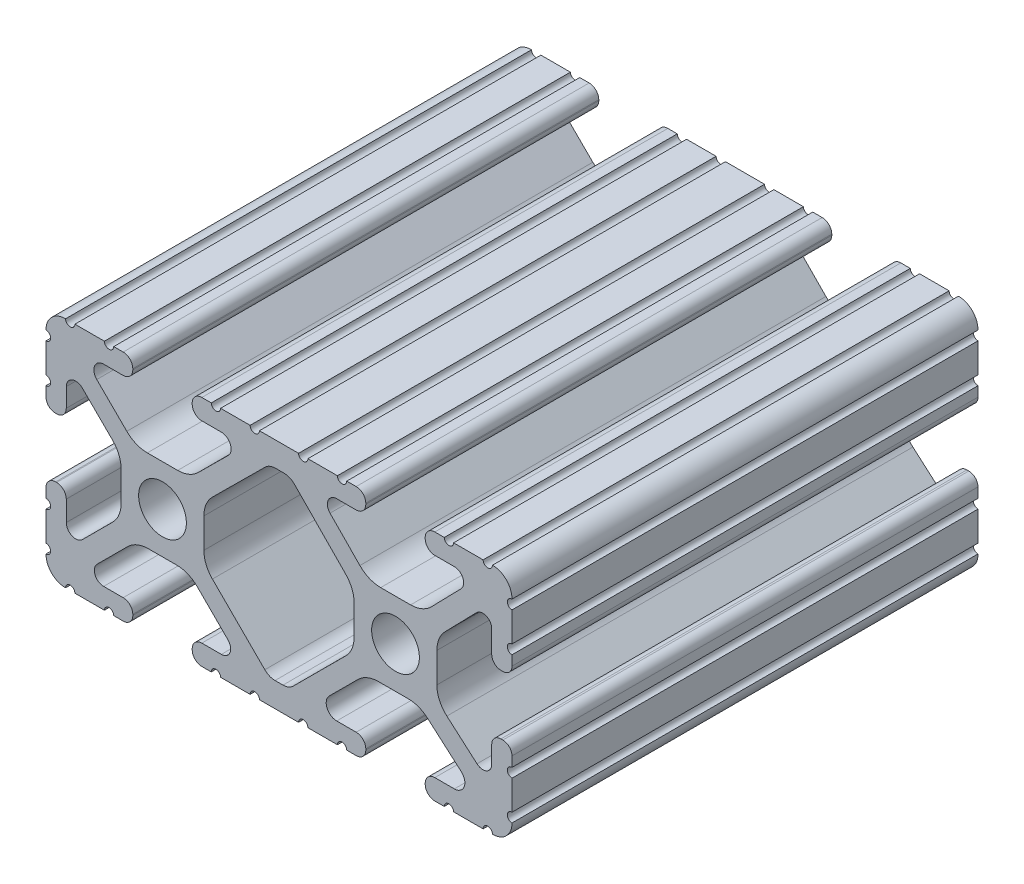
from build123d import *

# Parameters (mm, degrees)
SKETCH1_R           = 2.6035
BOSS_EXTRUDE1_DEPTH = 25.4


with BuildPart() as part:
    # Sketch1 → Boss-Extrude1 (new body, symmetric)
    with BuildSketch(Plane.XY):
        with BuildLine():
            Line((18.01710265, 12.7), (16.98745015, 12.7))
            ThreePointArc((16.98745015, 12.7), (16.245730386, 12.392769614), (15.9385, 11.65104985))
            Line((15.9385, 11.65104985), (15.9385, 11.53922))
            ThreePointArc((15.9385, 11.53922), (16.245750844, 10.797450844), (16.98752, 10.4902))
            Line((16.98752, 10.4902), (19.116384363, 10.4902))
            ThreePointArc((19.116384363, 10.4902), (20.052502933, 9.869096983), (19.844087081, 8.765172272))
            Line((19.844087081, 8.765172272), (16.618993479, 5.455112286))
            ThreePointArc((16.618993479, 5.455112286), (15.578994274, 4.745442459), (14.344932584, 4.4958))
            Line((14.344932584, 4.4958), (11.083317835, 4.4958))
            ThreePointArc((11.083317835, 4.4958), (9.854330953, 4.743306833), (8.816955189, 5.447238587))
            Line((8.816955189, 5.447238587), (5.564154119, 8.762652677))
            ThreePointArc((5.564154119, 8.762652677), (5.352591412, 9.867473037), (6.289393385, 10.4902))
            Line((6.289393385, 10.4902), (8.41248, 10.4902))
            ThreePointArc((8.41248, 10.4902), (9.154249156, 10.797450844), (9.4615, 11.53922))
            Line((9.4615, 11.53922), (9.4615, 11.65104985))
            ThreePointArc((9.4615, 11.65104985), (9.154269614, 12.392769614), (8.41254985, 12.7))
            Line((8.41254985, 12.7), (7.38288465, 12.7))
            ThreePointArc((7.38288465, 12.7), (6.87488465, 12.192), (6.36688465, 12.7))
            Line((6.36688465, 12.7), (3.14958095, 12.7))
            ThreePointArc((3.14958095, 12.7), (2.64158095, 12.192), (2.13358095, 12.7))
            Line((2.13358095, 12.7), (-2.13358095, 12.7))
            ThreePointArc((-2.13358095, 12.7), (-2.64158095, 12.192), (-3.14958095, 12.7))
            Line((-3.14958095, 12.7), (-6.36689735, 12.7))
            ThreePointArc((-6.36689735, 12.7), (-6.87489735, 12.192), (-7.38289735, 12.7))
            Line((-7.38289735, 12.7), (-8.41254985, 12.7))
            ThreePointArc((-8.41254985, 12.7), (-9.154269614, 12.392769614), (-9.4615, 11.65104985))
            Line((-9.4615, 11.65104985), (-9.4615, 11.53922))
            ThreePointArc((-9.4615, 11.53922), (-9.154249156, 10.797450844), (-8.41248, 10.4902))
            Line((-8.41248, 10.4902), (-6.283641037, 10.4902))
            ThreePointArc((-6.283641037, 10.4902), (-5.297291557, 9.829633109), (-5.532576693, 8.666071843))
            Line((-5.532576693, 8.666071843), (-8.809985098, 5.416263103))
            ThreePointArc((-8.809985098, 5.416263103), (-9.836720513, 4.734920264), (-11.045536121, 4.4958))
            Line((-11.045536121, 4.4958), (-14.354463879, 4.4958))
            ThreePointArc((-14.354463879, 4.4958), (-15.563279487, 4.734920264), (-16.590014902, 5.416263103))
            Line((-16.590014902, 5.416263103), (-19.867423307, 8.666071843))
            ThreePointArc((-19.867423307, 8.666071843), (-20.102708443, 9.829633109), (-19.116358963, 10.4902))
            Line((-19.116358963, 10.4902), (-16.98752, 10.4902))
            ThreePointArc((-16.98752, 10.4902), (-16.245750844, 10.797450844), (-15.9385, 11.53922))
            Line((-15.9385, 11.53922), (-15.9385, 11.65104985))
            ThreePointArc((-15.9385, 11.65104985), (-16.245730386, 12.392769614), (-16.98745015, 12.7))
            Line((-16.98745015, 12.7), (-18.01711535, 12.7))
            ThreePointArc((-18.01711535, 12.7), (-18.52511535, 12.192), (-19.03311535, 12.7))
            Line((-19.03311535, 12.7), (-22.2504, 12.7))
            ThreePointArc((-22.2504, 12.7), (-22.758323491, 12.192000006), (-23.266399977, 12.699846982))
            ThreePointArc((-23.266399977, 12.699846982), (-24.782522516, 12.082522516), (-25.399846982, 10.566399977))
            ThreePointArc((-25.399846982, 10.566399977), (-24.892000006, 10.058323491), (-25.4, 9.5504))
            Line((-25.4, 9.5504), (-25.4, 6.3330836))
            ThreePointArc((-25.4, 6.3330836), (-24.892, 5.8250836), (-25.4, 5.3170836))
            Line((-25.4, 5.3170836), (-25.4, 4.237520184))
            ThreePointArc((-25.4, 4.237520184), (-25.107393763, 3.531106237), (-24.400979816, 3.2385))
            Line((-24.400979816, 3.2385), (-24.23922, 3.2385))
            ThreePointArc((-24.23922, 3.2385), (-23.497450844, 3.545750844), (-23.1902, 4.28752))
            Line((-23.1902, 4.28752), (-23.1902, 6.334741132))
            ThreePointArc((-23.1902, 6.334741132), (-22.556026952, 7.286023527), (-21.434002553, 7.066535717))
            Line((-21.434002553, 7.066535717), (-18.147950853, 3.808156468))
            ThreePointArc((-18.147950853, 3.808156468), (-17.452759693, 2.774838327), (-17.208501877, 1.553619571))
            Line((-17.208501877, 1.553619571), (-17.208501877, -1.695179196))
            ThreePointArc((-17.208501877, -1.695179196), (-17.450738657, -2.911536421), (-18.140486065, -3.942289578))
            Line((-18.140486065, -3.942289578), (-21.431579576, -7.227386226))
            ThreePointArc((-21.431579576, -7.227386226), (-22.55444896, -7.449940594), (-23.1902, -6.498002195))
            Line((-23.1902, -6.498002195), (-23.1902, -4.28752))
            ThreePointArc((-23.1902, -4.28752), (-23.497450844, -3.545750844), (-24.23922, -3.2385))
            Line((-24.23922, -3.2385), (-24.35098, -3.2385))
            ThreePointArc((-24.35098, -3.2385), (-25.092749156, -3.545750844), (-25.4, -4.28752))
            Line((-25.4, -4.28752), (-25.4, -5.3171344))
            ThreePointArc((-25.4, -5.3171344), (-24.892, -5.8251344), (-25.4, -6.3331344))
            Line((-25.4, -6.3331344), (-25.4, -9.5504))
            ThreePointArc((-25.4, -9.5504), (-24.892000006, -10.058323491), (-25.399846982, -10.566399977))
            ThreePointArc((-25.399846982, -10.566399977), (-24.782522516, -12.082522516), (-23.266399977, -12.699846982))
            ThreePointArc((-23.266399977, -12.699846982), (-22.758323491, -12.192000006), (-22.2504, -12.7))
            Line((-22.2504, -12.7), (-19.03308995, -12.7))
            ThreePointArc((-19.03308995, -12.7), (-18.52508995, -12.192), (-18.01708995, -12.7))
            Line((-18.01708995, -12.7), (-16.9874692, -12.7))
            ThreePointArc((-16.9874692, -12.7), (-16.245700044, -12.392749156), (-15.9384492, -11.65098))
            Line((-15.9384492, -11.65098), (-15.9384492, -11.53922))
            ThreePointArc((-15.9384492, -11.53922), (-16.245700044, -10.797450844), (-16.9874692, -10.4902))
            Line((-16.9874692, -10.4902), (-19.116358963, -10.4902))
            ThreePointArc((-19.116358963, -10.4902), (-20.055197748, -9.862578342), (-19.834124023, -8.755124678))
            Line((-19.834124023, -8.755124678), (-16.49660751, -5.423689618))
            ThreePointArc((-16.49660751, -5.423689618), (-15.467274017, -4.736928798), (-14.253591699, -4.4958))
            Line((-14.253591699, -4.4958), (-11.146408301, -4.4958))
            ThreePointArc((-11.146408301, -4.4958), (-9.932725983, -4.736928798), (-8.90339249, -5.423689618))
            Line((-8.90339249, -5.423689618), (-5.565875977, -8.755124678))
            ThreePointArc((-5.565875977, -8.755124678), (-5.344802252, -9.862578342), (-6.283641037, -10.4902))
            Line((-6.283641037, -10.4902), (-8.4125308, -10.4902))
            ThreePointArc((-8.4125308, -10.4902), (-9.154299956, -10.797450844), (-9.4615508, -11.53922))
            Line((-9.4615508, -11.53922), (-9.4615508, -11.65098))
            ThreePointArc((-9.4615508, -11.65098), (-9.154299956, -12.392749156), (-8.4125308, -12.7))
            Line((-8.4125308, -12.7), (-7.38287195, -12.7))
            ThreePointArc((-7.38287195, -12.7), (-6.87487195, -12.192), (-6.36687195, -12.7))
            Line((-6.36687195, -12.7), (-3.14960635, -12.7))
            ThreePointArc((-3.14960635, -12.7), (-2.64160635, -12.192), (-2.13360635, -12.7))
            Line((-2.13360635, -12.7), (2.13360635, -12.7))
            ThreePointArc((2.13360635, -12.7), (2.64159365, -12.1920127), (3.14958095, -12.7))
            Line((3.14958095, -12.7), (6.36691005, -12.7))
            ThreePointArc((6.36691005, -12.7), (6.87491005, -12.192), (7.38291005, -12.7))
            Line((7.38291005, -12.7), (8.4125308, -12.7))
            ThreePointArc((8.4125308, -12.7), (9.154299956, -12.392749156), (9.4615508, -11.65098))
            Line((9.4615508, -11.65098), (9.4615508, -11.53922))
            ThreePointArc((9.4615508, -11.53922), (9.154299956, -10.797450844), (8.4125308, -10.4902))
            Line((8.4125308, -10.4902), (6.289393385, -10.4902))
            ThreePointArc((6.289393385, -10.4902), (5.231590322, -9.783049717), (5.480677245, -8.535265862))
            Line((5.480677245, -8.535265862), (8.597933595, -5.423689618))
            ThreePointArc((8.597933595, -5.423689618), (9.627267088, -4.736928798), (10.840949406, -4.4958))
            Line((10.840949406, -4.4958), (14.102564155, -4.4958))
            ThreePointArc((14.102564155, -4.4958), (15.215927525, -4.697410182), (16.187895372, -5.276636531))
            Line((16.187895372, -5.276636531), (19.868247549, -8.482246082))
            ThreePointArc((19.868247549, -8.482246082), (20.188435806, -9.746879864), (19.116384363, -10.4902))
            Line((19.116384363, -10.4902), (16.9874692, -10.4902))
            ThreePointArc((16.9874692, -10.4902), (16.245700044, -10.797450844), (15.9384492, -11.53922))
            Line((15.9384492, -11.53922), (15.9384492, -11.65098))
            ThreePointArc((15.9384492, -11.65098), (16.245700044, -12.392749156), (16.9874692, -12.7))
            Line((16.9874692, -12.7), (18.01710265, -12.7))
            ThreePointArc((18.01710265, -12.7), (18.52510265, -12.192), (19.03310265, -12.7))
            Line((19.03310265, -12.7), (22.2504, -12.7))
            ThreePointArc((22.2504, -12.7), (22.758323491, -12.192000006), (23.266399977, -12.699846982))
            ThreePointArc((23.266399977, -12.699846982), (24.782522516, -12.082522516), (25.399846982, -10.566399977))
            ThreePointArc((25.399846982, -10.566399977), (24.892000006, -10.058323492), (25.4, -9.550400001))
            Line((25.4, -9.550400001), (25.4, -6.333083592))
            ThreePointArc((25.4, -6.333083592), (24.892000001, -5.825083593), (25.4, -5.317083593))
            Line((25.4, -5.317083593), (25.4, -4.237520184))
            ThreePointArc((25.4, -4.237520184), (25.107393763, -3.531106237), (24.400979816, -3.2385))
            Line((24.400979816, -3.2385), (24.189220184, -3.2385))
            ThreePointArc((24.189220184, -3.2385), (23.482806237, -3.531106237), (23.1902, -4.237520184))
            Line((23.1902, -4.237520184), (23.1902, -6.155876159))
            ThreePointArc((23.1902, -6.155876159), (22.62232736, -7.038258539), (21.583974541, -6.886926384))
            Line((21.583974541, -6.886926384), (18.29817066, -4.024970844))
            ThreePointArc((18.29817066, -4.024970844), (17.493730985, -2.946044689), (17.208501877, -1.630807374))
            Line((17.208501877, -1.630807374), (17.208501877, 1.630807374))
            ThreePointArc((17.208501877, 1.630807374), (17.442348332, 2.82673414), (18.109440981, 3.846495088))
            Line((18.109440981, 3.846495088), (21.526346532, 7.353420386))
            ThreePointArc((21.526346532, 7.353420386), (22.585896263, 7.574939077), (23.1902, 6.676867167))
            Line((23.1902, 6.676867167), (23.1902, 4.237520184))
            ThreePointArc((23.1902, 4.237520184), (23.482806237, 3.531106237), (24.189220184, 3.2385))
            Line((24.189220184, 3.2385), (24.400979816, 3.2385))
            ThreePointArc((24.400979816, 3.2385), (25.107393763, 3.531106237), (25.4, 4.237520184))
            Line((25.4, 4.237520184), (25.4, 5.3170836))
            ThreePointArc((25.4, 5.3170836), (24.891949193, 5.825134407), (25.4, 6.333185215))
            Line((25.4, 6.333185215), (25.4, 9.550400015))
            ThreePointArc((25.4, 9.550400015), (24.892000013, 10.058323498), (25.399846982, 10.566399977))
            ThreePointArc((25.399846982, 10.566399977), (24.782522516, 12.082522516), (23.266399977, 12.699846982))
            ThreePointArc((23.266399977, 12.699846982), (22.758323491, 12.192000006), (22.2504, 12.7))
            Line((22.2504, 12.7), (19.03310265, 12.7))
            ThreePointArc((19.03310265, 12.7), (18.52510265, 12.192), (18.01710265, 12.7))
        make_face()
        with Locations((-12.7, 0)):
            Circle(SKETCH1_R, mode=Mode.SUBTRACT)
        with Locations((12.7, 0)):
            Circle(SKETCH1_R, mode=Mode.SUBTRACT)
        with BuildLine():
            Line((-7.259513935, -3.869413038), (-1.545748891, -9.572766749))
            ThreePointArc((-1.545748891, -9.572766749), (-1.035199478, -9.913400116), (-0.433213048, -10.033))
            Line((-0.433213048, -10.033), (0.433213048, -10.033))
            ThreePointArc((0.433213048, -10.033), (1.035199478, -9.913400116), (1.545748891, -9.572766749))
            Line((1.545748891, -9.572766749), (7.259513935, -3.869413038))
            ThreePointArc((7.259513935, -3.869413038), (7.949261343, -2.838659881), (8.191498123, -1.622302656))
            Line((8.191498123, -1.622302656), (8.191498123, 1.622302656))
            ThreePointArc((8.191498123, 1.622302656), (7.955573352, 2.823327967), (7.282860769, 3.845864069))
            Line((7.282860769, 3.845864069), (1.675572808, 9.561086461))
            ThreePointArc((1.675572808, 9.561086461), (1.161034429, 9.910236611), (0.551456936, 10.033))
            Line((0.551456936, 10.033), (-0.395199982, 10.033))
            ThreePointArc((-0.395199982, 10.033), (-0.994772524, 9.914396349), (-1.50403329, 9.576450301))
            Line((-1.50403329, 9.576450301), (-7.252049147, 3.876839553))
            ThreePointArc((-7.252049147, 3.876839553), (-7.947240307, 2.843521412), (-8.191498123, 1.622302656))
            Line((-8.191498123, 1.622302656), (-8.191498123, -1.622302656))
            ThreePointArc((-8.191498123, -1.622302656), (-7.949261343, -2.838659881), (-7.259513935, -3.869413038))
        make_face(mode=Mode.SUBTRACT)
    extrude(amount=BOSS_EXTRUDE1_DEPTH, both=True)


solid = part.part
